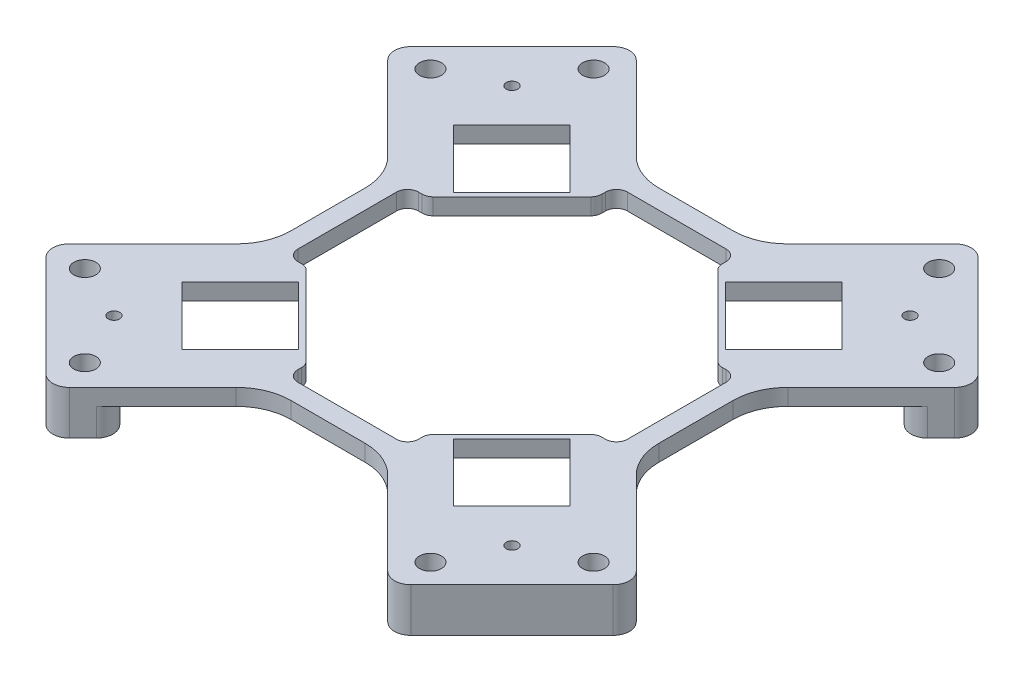
from build123d import *

# Parameters (mm, degrees)
BOSS_EXTRUDE1_DEPTH     = 3
BOSS_EXTRUDE2_DEPTH     = 5
CUT_EXTRUDE1_DEPTH      = 3
SKETCH1_R               = 2
CUT_EXTRUDE2_DEPTH      = 4
CUT_EXTRUDE2_DEPTH_BACK = 6
CUT_EXTRUDE4_DEPTH      = 10
FILLET1_R               = 3
FILLET2_R               = 10
CUT_EXTRUDE5_DEPTH      = 10
SKETCH9_W               = 5
SKETCH9_H               = 21.953318806
SKETCH9_W_2             = 21.953318806
SKETCH9_H_2             = 5
CUT_EXTRUDE6_DEPTH      = 10
FILLET3_R               = 2
SKETCH10_R              = 1.05
CUT_EXTRUDE7_DEPTH      = 10
CUT_EXTRUDE7_DEPTH_BACK = 10
SKETCH11_R              = 4
SKETCH11_R_2            = 1.05
BOSS_EXTRUDE3_DEPTH     = 2
SKETCH13_R              = 4
CUT_EXTRUDE9_DEPTH      = 10


with BuildPart() as part:
    # Sketch3 → Boss-Extrude1 (new body)
    with BuildSketch(Plane(origin=(0, 0, 0), x_dir=(1, 0, 0), z_dir=(0, 1, 0))):
        Polygon((-53.74011537, 31.112698372), (-31.112698372, 53.74011537), (31.112698372, 53.74011537), (53.74011537, 31.112698372), (53.74011537, -31.112698372), (31.112698372, -53.74011537), (-31.112698372, -53.74011537), (-53.74011537, -31.112698372), align=None)
    extrude(amount=BOSS_EXTRUDE1_DEPTH)

    # Sketch4 → Boss-Extrude2 (add)
    with BuildSketch(Plane(origin=(0, 0, 0), x_dir=(-1, 0, 0), z_dir=(0, -1, 0))):
        Polygon((53.74011537, -31.112698372), (31.112698372, -53.74011537), (24.395183951, -47.022600949), (47.022600949, -24.395183951), align=None)
        Polygon((31.112698372, 53.74011537), (24.395183951, 47.022600949), (47.022600949, 24.395183951), (53.74011537, 31.112698372), align=None)
        Polygon((-31.112698372, 53.74011537), (-24.395183951, 47.022600949), (-47.022600949, 24.395183951), (-53.74011537, 31.112698372), align=None)
        Polygon((-47.022600949, -24.395183951), (-53.74011537, -31.112698372), (-31.112698372, -53.74011537), (-24.395183951, -47.022600949), align=None)
    extrude(amount=BOSS_EXTRUDE2_DEPTH)

    # Sketch2 → Cut-Extrude1 (cut)
    with BuildSketch(Plane(origin=(0, 0, 0), x_dir=(1, 0, 0), z_dir=(0, 1, 0))):
        Polygon((-35.355339059, 24.748737342), (-24.748737342, 35.355339059), (-14.142135624, 24.748737342), (-24.748737342, 14.142135624), align=None)
        Polygon((14.142135624, 24.748737342), (24.748737342, 14.142135624), (35.355339059, 24.748737342), (24.748737342, 35.355339059), align=None)
        Polygon((-14.142135624, -24.748737342), (-24.748737342, -14.142135624), (-35.355339059, -24.748737342), (-24.748737342, -35.355339059), align=None)
        Polygon((14.142135624, -24.748737342), (24.748737342, -14.142135624), (35.355339059, -24.748737342), (24.748737342, -35.355339059), align=None)
    extrude(amount=CUT_EXTRUDE1_DEPTH, mode=Mode.SUBTRACT)

    # Sketch1 → Cut-Extrude2 (cut, two sides)
    with BuildSketch(Plane(origin=(0, 0, 0), x_dir=(1, 0, 0), z_dir=(0, 1, 0))) as cut_extrude2_sk:
        with Locations((31.466251763, 46.315494168)):
            Circle(SKETCH1_R)
        with Locations((46.315494168, 31.466251763)):
            Circle(SKETCH1_R)
        with Locations((46.315494168, -31.466251763)):
            Circle(SKETCH1_R)
        with Locations((31.466251763, -46.315494168)):
            Circle(SKETCH1_R)
        with Locations((-31.466251763, -46.315494168)):
            Circle(SKETCH1_R)
        with Locations((-46.315494168, -31.466251763)):
            Circle(SKETCH1_R)
        with Locations((-46.315494168, 31.466251763)):
            Circle(SKETCH1_R)
        with Locations((-31.466251763, 46.315494168)):
            Circle(SKETCH1_R)
    extrude(amount=CUT_EXTRUDE2_DEPTH, mode=Mode.SUBTRACT)
    extrude(cut_extrude2_sk.sketch, amount=-CUT_EXTRUDE2_DEPTH_BACK, mode=Mode.SUBTRACT)

    # Sketch5 → Cut-Extrude4 (cut)
    with BuildSketch(Plane(origin=(0, 0, 0), x_dir=(1, 0, 0), z_dir=(0, 1, 0))):
        Polygon((-53.74011537, -31.112698372), (-33.5, -10.872583002), (-33.5, 10.872583002), (-53.74011537, 31.112698372), align=None)
        Polygon((53.74011537, -31.112698372), (33.5, -10.872583002), (33.5, 10.872583002), (53.74011537, 31.112698372), align=None)
        Polygon((-31.112698372, -53.74011537), (31.112698372, -53.74011537), (10.872583002, -33.5), (-10.872583002, -33.5), align=None)
        Polygon((-31.112698372, 53.74011537), (31.112698372, 53.74011537), (10.872583002, 33.5), (-10.872583002, 33.5), align=None)
    extrude(amount=CUT_EXTRUDE4_DEPTH, mode=Mode.SUBTRACT)

    # Fillet1
    fillet1_edges = [part.edges().sort_by_distance(p)[0] for p in [
        (-53.74011537, -1, -31.112698372),
        (-31.112698372, -1, -53.74011537),
        (31.112698372, -1, -53.74011537),
        (53.74011537, -1, -31.112698372),
        (53.74011537, -1, 31.112698372),
        (31.112698372, -1, 53.74011537),
        (-31.112698372, -1, 53.74011537),
        (-53.74011537, -1, 31.112698372),
        (-47.022600949, -2.5, 24.395183951),
        (-24.395183951, -2.5, 47.022600949),
        (-24.395183951, -2.5, -47.022600949),
        (-47.022600949, -2.5, -24.395183951),
        (47.022600949, -2.5, -24.395183951),
        (24.395183951, -2.5, -47.022600949),
        (24.395183951, -2.5, 47.022600949),
        (47.022600949, -2.5, 24.395183951),
    ]]
    fillet(fillet1_edges, radius=FILLET1_R)

    # Fillet2
    fillet2_edges = [part.edges().sort_by_distance(p)[0] for p in [
        (-33.5, 1.5, 10.872583002),
        (-33.5, 1.5, -10.872583002),
        (33.5, 1.5, -10.872583002),
        (33.5, 1.5, 10.872583002),
        (10.872583002, 1.5, 33.5),
        (-10.872583002, 1.5, 33.5),
        (-10.872583002, 1.5, -33.5),
        (10.872583002, 1.5, -33.5),
    ]]
    fillet(fillet2_edges, radius=FILLET2_R)

    # Sketch8 → Cut-Extrude5 (cut)
    with BuildSketch(Plane.XZ):
        Polygon((-26.5, 10.976659403), (-10.976659403, 26.5), (10.976659403, 26.5), (26.5, 10.976659403), (26.5, -10.976659403), (10.976659403, -26.5), (-10.976659403, -26.5), (-26.5, -10.976659403), align=None)
    extrude(amount=-CUT_EXTRUDE5_DEPTH, mode=Mode.SUBTRACT)

    # Sketch9 → Cut-Extrude6 (cut)
    with BuildSketch(Plane.XZ):
        with Locations((-27.5, 0)):
            Rectangle(SKETCH9_W, SKETCH9_H)
        with Locations((0, 27.5)):
            Rectangle(SKETCH9_W_2, SKETCH9_H_2)
        with Locations((27.5, 0)):
            Rectangle(SKETCH9_W, SKETCH9_H)
        with Locations((0, -27.5)):
            Rectangle(SKETCH9_W_2, SKETCH9_H_2)
    extrude(amount=-CUT_EXTRUDE6_DEPTH, mode=Mode.SUBTRACT)

    # Fillet3
    fillet3_edges = [part.edges().sort_by_distance(p)[0] for p in [
        (-26.5, 1.5, -10.976659403),
        (-26.5, 1.5, 10.976659403),
        (-10.976659403, 1.5, 26.5),
        (10.976659403, 1.5, 26.5),
        (26.5, 1.5, 10.976659403),
        (26.5, 1.5, -10.976659403),
        (10.976659403, 1.5, -26.5),
        (-10.976659403, 1.5, -26.5),
        (-30, 1.5, -10.976659403),
        (-30, 1.5, 10.976659403),
        (-10.976659403, 1.5, 30),
        (10.976659403, 1.5, 30),
        (30, 1.5, 10.976659403),
        (30, 1.5, -10.976659403),
        (10.976659403, 1.5, -30),
        (-10.976659403, 1.5, -30),
    ]]
    fillet(fillet3_edges, radius=FILLET3_R)

    # Sketch10 → Cut-Extrude7 (cut, two sides)
    with BuildSketch(Plane(origin=(0, 0, 0), x_dir=(1, 0, 0), z_dir=(0, 1, 0))) as cut_extrude7_sk:
        with Locations((36.239222536, 36.239222536)):
            Circle(SKETCH10_R)
        with Locations((-36.239222536, -36.239222536)):
            Circle(SKETCH10_R)
        with Locations((-36.239222536, 36.239222536)):
            Circle(SKETCH10_R)
        with Locations((36.239222536, -36.239222536)):
            Circle(SKETCH10_R)
    extrude(amount=CUT_EXTRUDE7_DEPTH, mode=Mode.SUBTRACT)
    extrude(cut_extrude7_sk.sketch, amount=-CUT_EXTRUDE7_DEPTH_BACK, mode=Mode.SUBTRACT)

    # Sketch11 → Boss-Extrude3 (add)
    with BuildSketch(Plane.XZ):
        with Locations((36.239222536, -36.239222536)):
            Circle(SKETCH11_R)
        with Locations((36.239222536, -36.239222536)):
            Circle(SKETCH11_R_2, mode=Mode.SUBTRACT)
        with Locations((-36.239222536, 36.239222536)):
            Circle(SKETCH11_R)
        with Locations((-36.239222536, 36.239222536)):
            Circle(SKETCH11_R_2, mode=Mode.SUBTRACT)
        with Locations((-36.239222536, -36.239222536)):
            Circle(SKETCH11_R)
        with Locations((-36.239222536, -36.239222536)):
            Circle(SKETCH11_R_2, mode=Mode.SUBTRACT)
        with Locations((36.239222536, 36.239222536)):
            Circle(SKETCH11_R)
        with Locations((36.239222536, 36.239222536)):
            Circle(SKETCH11_R_2, mode=Mode.SUBTRACT)
    extrude(amount=BOSS_EXTRUDE3_DEPTH)

    # Sketch13 → Cut-Extrude9 (cut)
    with BuildSketch(Plane.XZ.offset(2)):
        with Locations((-36.239222536, 36.239222536)):
            Circle(SKETCH13_R)
        with Locations((36.239222536, 36.239222536)):
            Circle(SKETCH13_R)
        with Locations((36.239222536, -36.239222536)):
            Circle(SKETCH13_R)
        with Locations((-36.239222536, -36.239222536)):
            Circle(SKETCH13_R)
    extrude(amount=CUT_EXTRUDE9_DEPTH, mode=Mode.SUBTRACT)


solid = part.part
